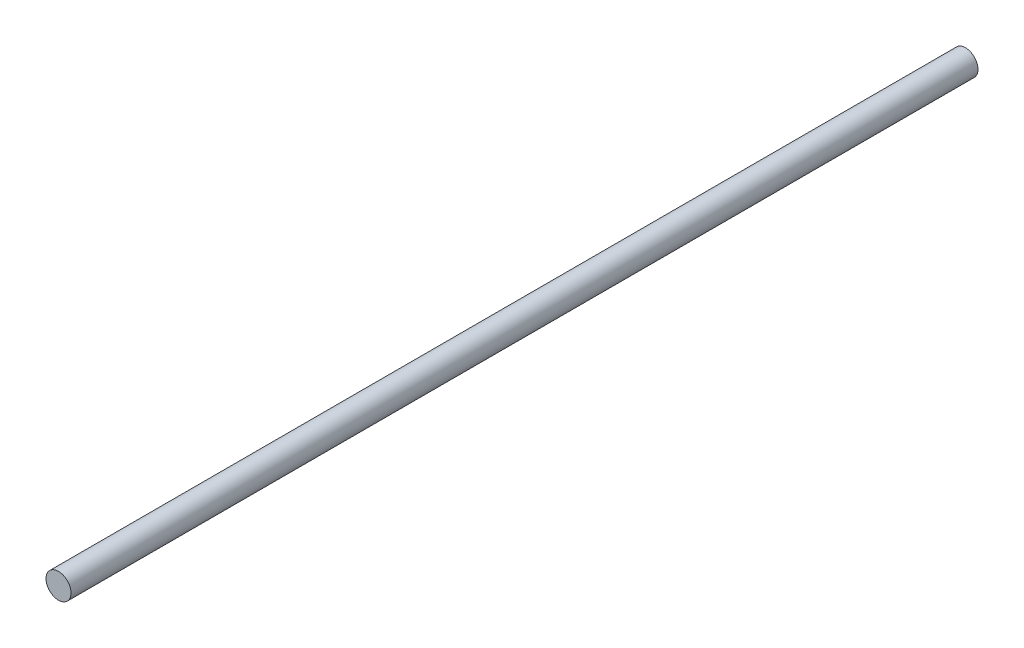
from build123d import *

# Parameters (mm, degrees)
ESBO_O1_R                = 4
RESSALTO_EXTRUS_O1_DEPTH = 145


with BuildPart() as part:
    # Esboço1 → Ressalto-extrusão1 (new body, symmetric)
    with BuildSketch(Plane.XY):
        Circle(ESBO_O1_R)
    extrude(amount=RESSALTO_EXTRUS_O1_DEPTH, both=True)


solid = part.part
